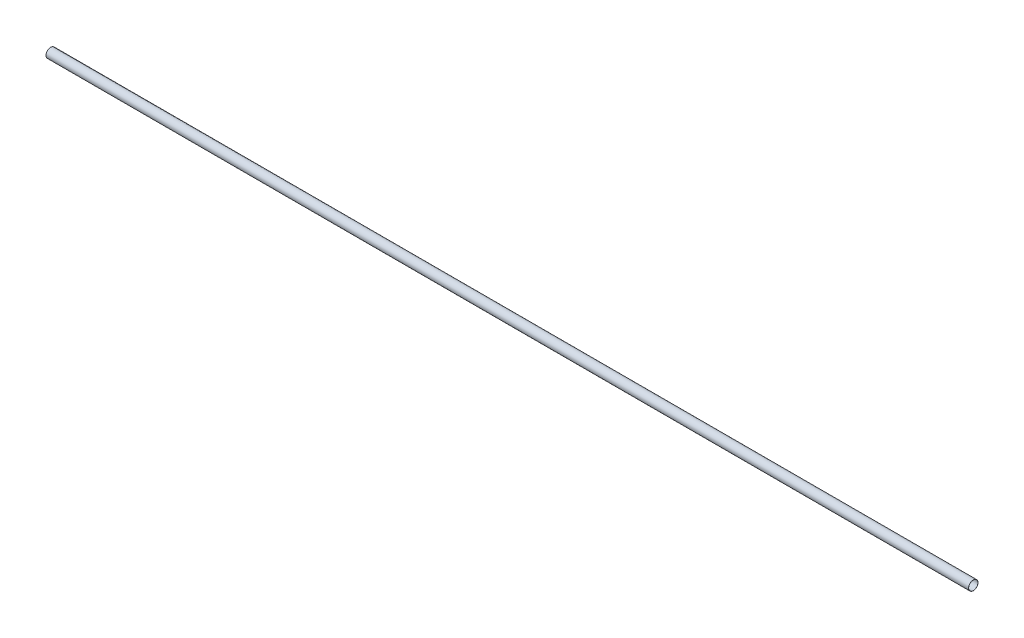
from build123d import *

# Parameters (mm, degrees)
SKETCH1_W          = 10000
SKETCH1_H          = 51
SKETCH1_W_2        = 9998
SKETCH1_H_2        = 49
SKETCH3_R          = 50
CUT_EXTRUDE1_DEPTH = 102101


with BuildPart() as part:
    # Sketch1 → Revolve1 (revolve)
    with BuildSketch(Plane.XY, mode=Mode.PRIVATE) as revolve1_sk:
        with Locations((5000, 25.5)):
            Rectangle(SKETCH1_W, SKETCH1_H)
        with Locations((5000, 25.5)):
            Rectangle(SKETCH1_W_2, SKETCH1_H_2, mode=Mode.SUBTRACT)
    revolve(revolve1_sk.sketch.rotate(Axis((0, 51, 0), (1, 0, 0)), 270), axis=Axis((0, 51, 0), (1, 0, 0)))

    # Sketch3 → Cut-Extrude1 (cut)
    with BuildSketch(Plane(origin=(10000, 0, 0), x_dir=(0, 0, -1), z_dir=(1, 0, 0))):
        with Locations(Location((0, 51, 0), (0, 0, 180))):
            Circle(SKETCH3_R)
    extrude(amount=-CUT_EXTRUDE1_DEPTH, mode=Mode.SUBTRACT)


solid = part.part
